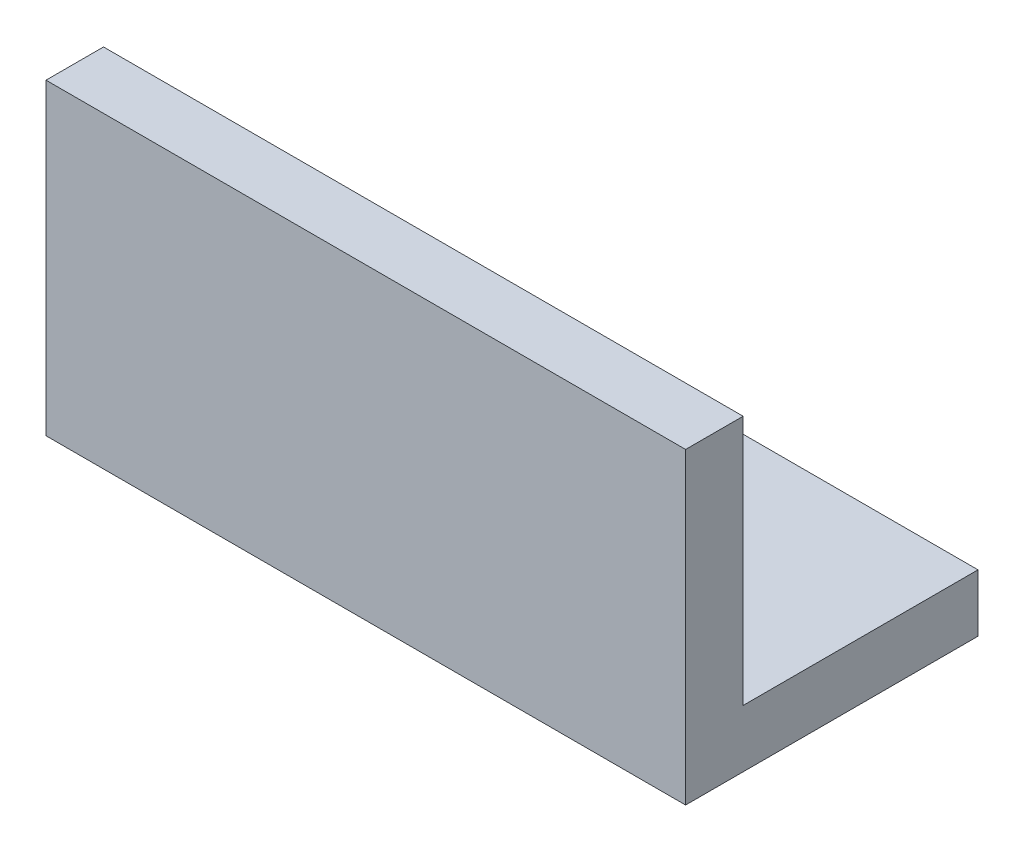
from build123d import *

# Parameters (mm, degrees)
SKETCH1_W               = 76.708
SKETCH1_H               = 32.2799964
SKETCH1_R               = 3.571875
MAIN_BODY_DEPTH         = 34
SKETCH13_W              = 76.708
SKETCH13_H              = 25.9299964
CUT_EXTRUDE1_DEPTH      = 27.65
SKETCH14_OUTSIDE_W      = 96.688
SKETCH14_OUTSIDE_H      = 52.26
SKETCH14_OUTSIDE_W_2    = 70.612
SKETCH14_OUTSIDE_H_2    = 32.2799964
CUT_EXTRUDE2_DEPTH      = 1
CUT_EXTRUDE2_DEPTH_BACK = 35


with BuildPart() as part:
    # Sketch1 → Main Body (new body)
    with BuildSketch(Plane(origin=(0, 0, 0), x_dir=(1, 0, 0), z_dir=(0, 1, 0))):
        with Locations((38.354, 16.1399982)):
            Rectangle(SKETCH1_W, SKETCH1_H)
        with Locations((19.177, 16.1399982)):
            Circle(SKETCH1_R, mode=Mode.SUBTRACT)
        with Locations((57.531, 16.1399982)):
            Circle(SKETCH1_R, mode=Mode.SUBTRACT)
    extrude(amount=MAIN_BODY_DEPTH)

    # Sketch13 → Cut-Extrude1 (cut)
    with BuildSketch(Plane(origin=(0, 34, 0), x_dir=(1, 0, 0), z_dir=(0, 1, 0))):
        with Locations((38.354, 19.3149982)):
            Rectangle(SKETCH13_W, SKETCH13_H)
    extrude(amount=-CUT_EXTRUDE1_DEPTH, mode=Mode.SUBTRACT)

    # Sketch14 outside → Cut-Extrude2 (cut, two sides)
    with BuildSketch(Plane.XZ) as cut_extrude2_sk:
        with Locations((38.354, -16.14)):
            Rectangle(SKETCH14_OUTSIDE_W, SKETCH14_OUTSIDE_H)
        with Locations((38.354, -16.1399982)):
            Rectangle(SKETCH14_OUTSIDE_W_2, SKETCH14_OUTSIDE_H_2, mode=Mode.SUBTRACT)
    extrude(amount=CUT_EXTRUDE2_DEPTH, mode=Mode.SUBTRACT)
    extrude(cut_extrude2_sk.sketch, amount=-CUT_EXTRUDE2_DEPTH_BACK, mode=Mode.SUBTRACT)


solid = part.part
